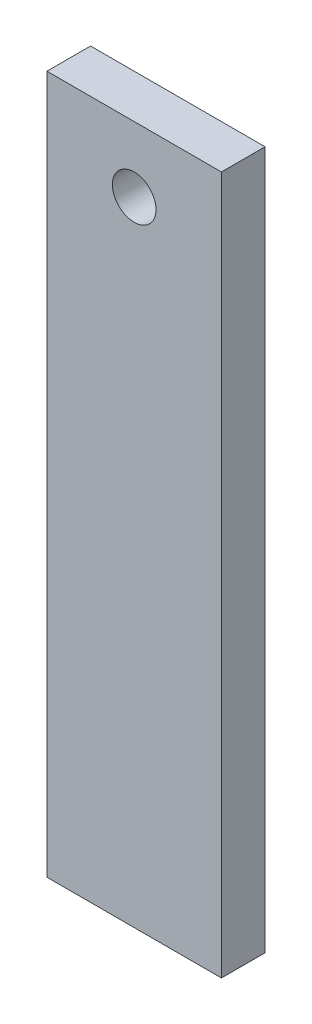
from build123d import *

# Parameters (mm, degrees)
SKETCH1_W                   = 50.8
SKETCH1_H                   = 203.2
BOSS_EXTRUDE1_DEPTH         = 12.7
F_1_4_20_TAPPED_HOLE1_D     = 5.1054
F_1_4_20_TAPPED_HOLE1_DEPTH = 25.4
F_1_4_20_TAPPED_HOLE1_TIP   = 1.533816902
SKETCH4_R                   = 6.35
CUT_EXTRUDE1_DEPTH          = 13.7


with BuildPart() as part:
    # Sketch1 → Boss-Extrude1 (new body)
    with BuildSketch(Plane.XY):
        with Locations((0, 101.6)):
            Rectangle(SKETCH1_W, SKETCH1_H)
    extrude(amount=BOSS_EXTRUDE1_DEPTH)

    # 1/4-20 Tapped Hole1
    with Locations(Plane(origin=(0, 0, 0), x_dir=(-1, 0, 0), z_dir=(0, -1, 0))):
        with Locations((15.875, -6.35), (-15.875, -6.35)):
            Hole(F_1_4_20_TAPPED_HOLE1_D / 2, depth=F_1_4_20_TAPPED_HOLE1_DEPTH)
            with Locations((0, 0, -(F_1_4_20_TAPPED_HOLE1_DEPTH + F_1_4_20_TAPPED_HOLE1_TIP / 2))):  # 118° drill point
                Cone(0, F_1_4_20_TAPPED_HOLE1_D / 2, F_1_4_20_TAPPED_HOLE1_TIP, mode=Mode.SUBTRACT)

    # Sketch4 → Cut-Extrude1 (cut, through all)
    with BuildSketch(Plane(origin=(0, 0, 0), x_dir=(-1, 0, 0), z_dir=(0, 0, -1))):
        with Locations((0, 184.15)):
            Circle(SKETCH4_R)
    extrude(amount=-CUT_EXTRUDE1_DEPTH, mode=Mode.SUBTRACT)


solid = part.part
